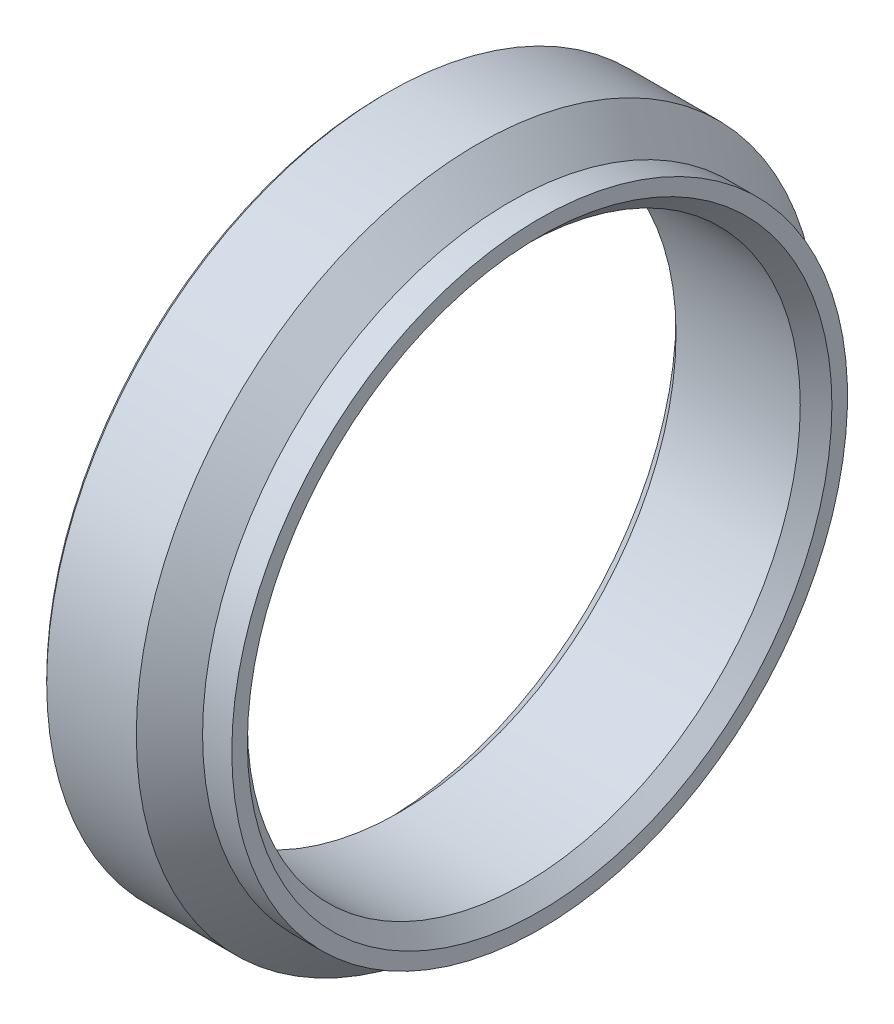
from build123d import *


with BuildPart() as part:
    # Sketch1 → Revolve1 (revolve)
    with BuildSketch(Plane.XY):
        Polygon((-8, 17.5), (-8, 15), (-7.188, 14.188), (-0.812, 14.188), (0, 15), (0, 15.8), (-1.5, 15.8), (-3.2, 17.5), align=None)
    revolve(axis=Axis((50, 0, 0), (-1, 0, 0)))

    # Sketch2 → Cut-Revolve1 (revolve, cut)
    with BuildSketch(Plane.XY):
        Polygon((-8, 17.3), (-7.8, 17.5), (0, 17.5), (0, 20), (-8, 20), align=None)
    revolve(axis=Axis((50, 0, 0), (-1, 0, 0)), mode=Mode.SUBTRACT)


solid = part.part
